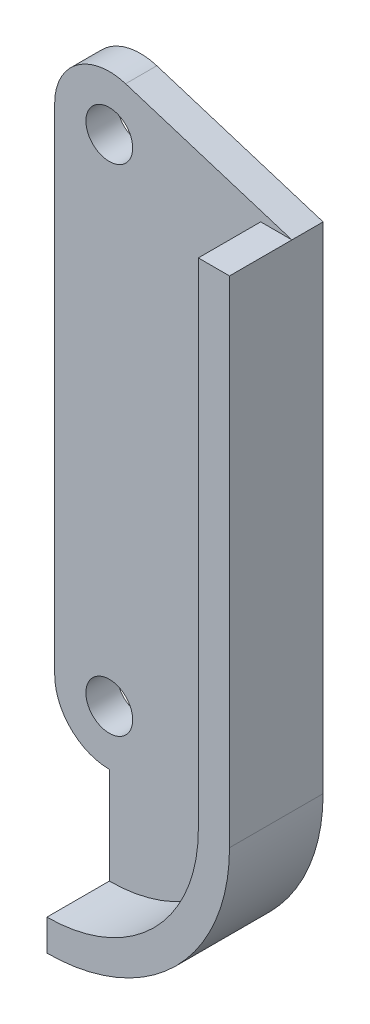
from build123d import *

# Parameters (mm, degrees)
SKETCH1_R           = 3.5
SKETCH1_R_2         = 1.5
BOSS_EXTRUDE1_DEPTH = 2
BOSS_EXTRUDE2_START = 2
BOSS_EXTRUDE2_DEPTH = 4


with BuildPart() as part:
    # Sketch1 → Boss-Extrude1 (new body)
    with BuildSketch(Plane.XY):
        with BuildLine():
            Line((9.70788, 31.75), (11.70788, 31.75))
            Line((11.70788, 31.75), (1.046303857, 35.089947341))
            ThreePointArc((1.046303857, 35.089947341), (2.820643854, 33.822189241), (3.5, 31.75))
            ThreePointArc((3.5, 31.75), (0, 28.25), (-3.5, 31.75))
            Line((-3.5, 31.75), (-3.5, 0))
            ThreePointArc((-3.5, 0), (0, 3.5), (3.5, 0))
            ThreePointArc((3.5, 0), (2.474873734, -2.474873734), (0, -3.5))
            Line((0, -3.5), (0, -9.70788))
            ThreePointArc((0, -9.70788), (6.864507779, -6.864507779), (9.70788, 0))
            Line((9.70788, 0), (9.70788, 31.75))
        make_face()
        with Locations((0, 31.75)):
            Circle(SKETCH1_R)
        with Locations((0, 31.75)):
            Circle(SKETCH1_R_2, mode=Mode.SUBTRACT)
        Circle(SKETCH1_R)
        Circle(SKETCH1_R_2, mode=Mode.SUBTRACT)
        with BuildLine():
            ThreePointArc((0, -9.70788), (6.864507779, -6.864507779), (9.70788, 0))
            Line((9.70788, 0), (9.70788, 31.75))
            Line((9.70788, 31.75), (11.70788, 31.75))
            Line((11.70788, 31.75), (11.70788, 0))
            ThreePointArc((11.70788, 0), (8.278721341, -8.278721341), (0, -11.70788))
            Line((0, -11.70788), (0, -9.70788))
        make_face()
    extrude(amount=BOSS_EXTRUDE1_DEPTH)

    # Sketch1_3 → Boss-Extrude2 (add)
    with BuildSketch(Plane.XY.offset(BOSS_EXTRUDE2_START)):
        with BuildLine():
            ThreePointArc((0, -9.70788), (6.864507779, -6.864507779), (9.70788, 0))
            Line((9.70788, 0), (9.70788, 31.75))
            Line((9.70788, 31.75), (11.70788, 31.75))
            Line((11.70788, 31.75), (11.70788, 0))
            ThreePointArc((11.70788, 0), (8.278721341, -8.278721341), (0, -11.70788))
            Line((0, -11.70788), (0, -9.70788))
        make_face()
    extrude(amount=BOSS_EXTRUDE2_DEPTH)


solid = part.part
